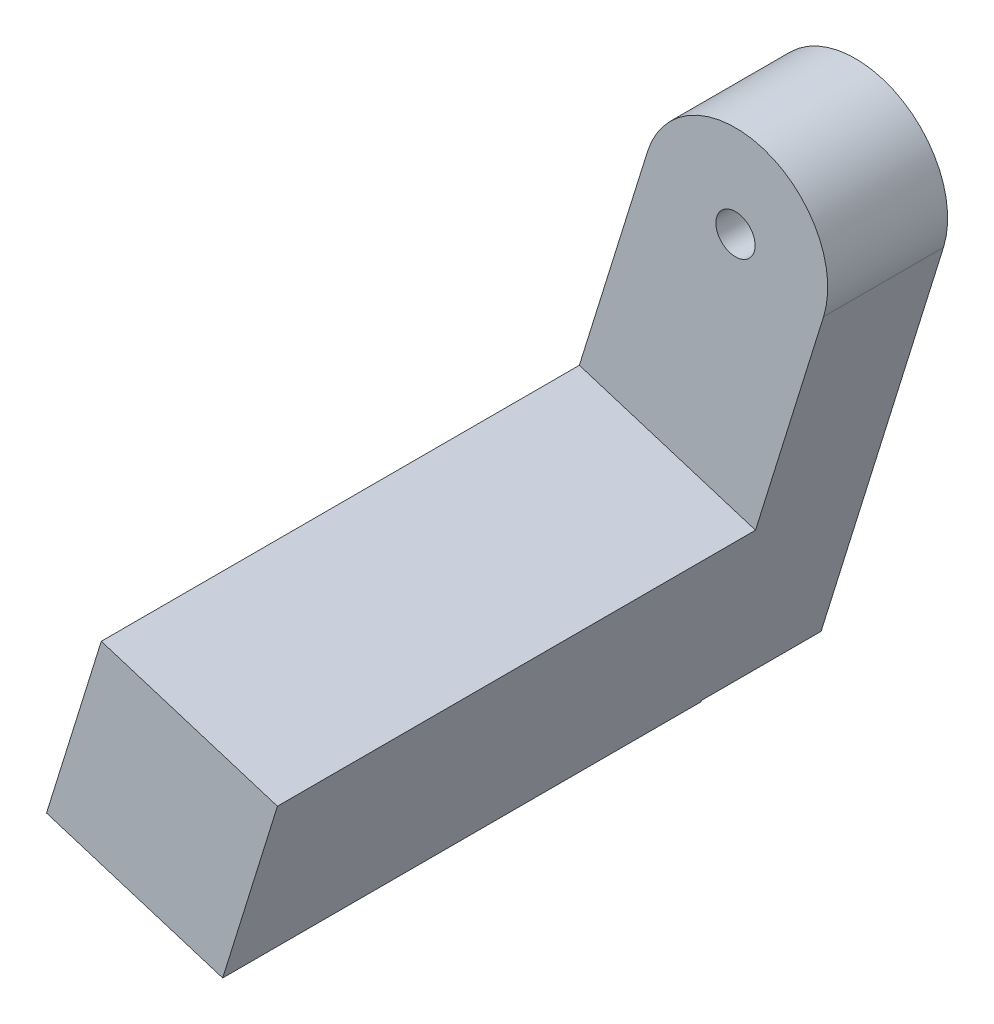
from build123d import *

# Parameters (mm, degrees)
SKETCH1_R           = 4
SKETCH1_R_2         = 2.3
BOSS_EXTRUDE1_DEPTH = 3.2
SKETCH2_R           = 4
SKETCH2_R_2         = 0.85
BOSS_EXTRUDE2_DEPTH = 2
BOSS_EXTRUDE3_DEPTH = 8
SKETCH6_R           = 0.85
CUT_EXTRUDE1_DEPTH  = 2


with BuildPart() as part:
    # Sketch1 → Boss-Extrude1 (new body)
    with BuildSketch(Plane.XY):
        Circle(SKETCH1_R)
        Circle(SKETCH1_R_2, mode=Mode.SUBTRACT)
    extrude(amount=-BOSS_EXTRUDE1_DEPTH)

    # Sketch2 → Boss-Extrude2 (add)
    with BuildSketch(Plane.XY):
        Circle(SKETCH2_R)
        Circle(SKETCH2_R_2, mode=Mode.SUBTRACT)
    extrude(amount=BOSS_EXTRUDE2_DEPTH)

    # Sketch5 → Boss-Extrude3 (add)
    with BuildSketch(Plane(origin=(3.819651946, -1.187543266, 0), x_dir=(0, 0, -1), z_dir=(0.954912987, -0.296885816, 0))):
        Polygon((-2, 0), (3.2, 0), (3.2, -17.878888538), (-2, -17.878888538), (-2, -17.94433562), (-22.731913212, -17.94433562), (-22.731913212, -9.94433562), (-2, -9.94433562), align=None)
    extrude(amount=-BOSS_EXTRUDE3_DEPTH)

    # Sketch6 → Cut-Extrude1 (cut)
    with BuildSketch(Plane.XY.offset(2)):
        Circle(SKETCH6_R)
    extrude(amount=-CUT_EXTRUDE1_DEPTH, mode=Mode.SUBTRACT)


solid = part.part
